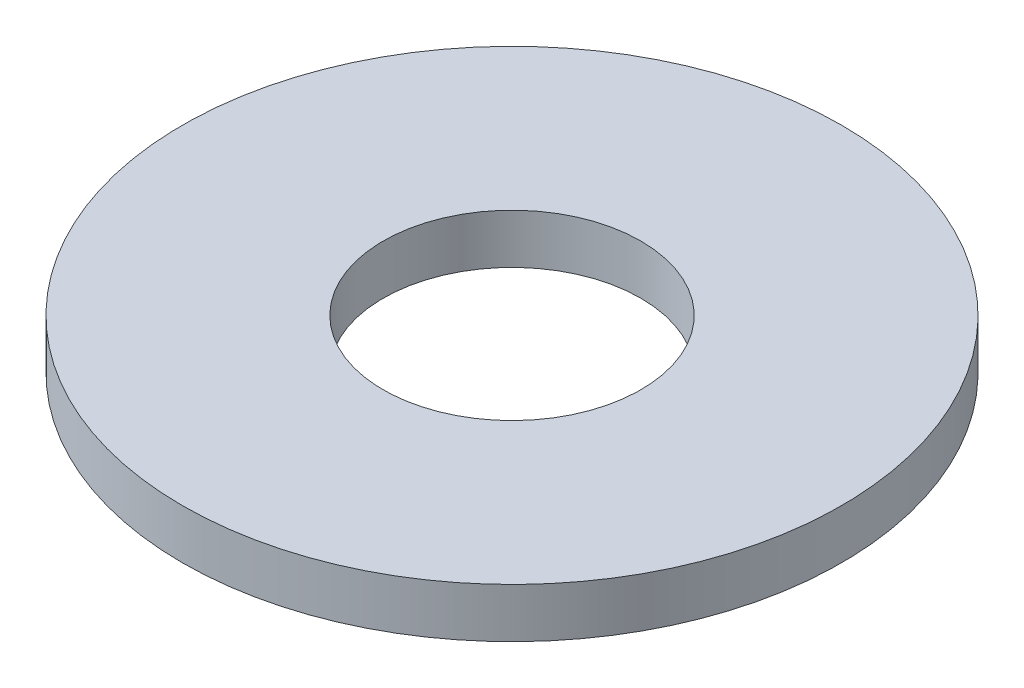
from build123d import *

# Parameters (mm, degrees)
SKETCH1_R           = 8.4455
BOSS_EXTRUDE1_DEPTH = 1.27
SKETCH2_R           = 3.302
CUT_EXTRUDE1_DEPTH  = 2.27


with BuildPart() as part:
    # Sketch1 → Boss-Extrude1 (new body)
    with BuildSketch(Plane(origin=(0, 0, 0), x_dir=(1, 0, 0), z_dir=(0, 1, 0))):
        Circle(SKETCH1_R)
    extrude(amount=BOSS_EXTRUDE1_DEPTH)

    # Sketch2 → Cut-Extrude1 (cut, through all)
    with BuildSketch(Plane(origin=(0, 0, 0), x_dir=(-1, 0, 0), z_dir=(0, -1, 0))):
        Circle(SKETCH2_R)
    extrude(amount=-CUT_EXTRUDE1_DEPTH, mode=Mode.SUBTRACT)


solid = part.part
